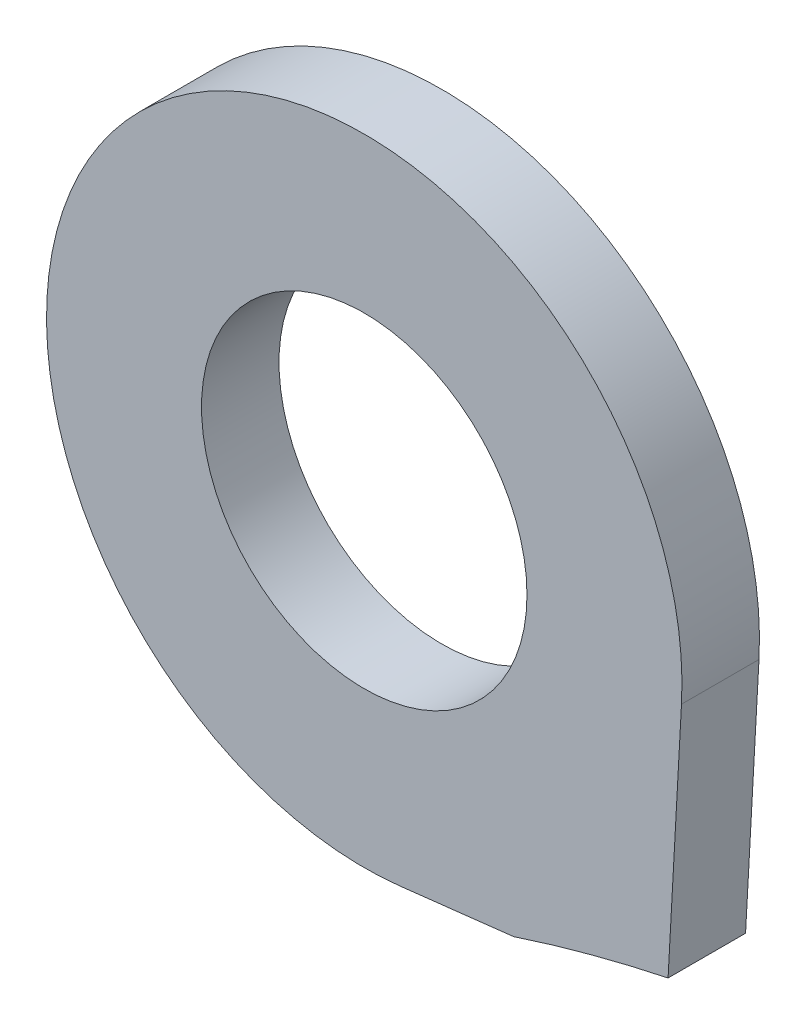
from build123d import *

# Parameters (mm, degrees)
SKETCH1_R           = 2.1
BOSS_EXTRUDE1_DEPTH = 1


with BuildPart() as part:
    # Sketch1 → Boss-Extrude1 (new body)
    with BuildSketch(Plane.XY):
        with BuildLine():
            Line((-5.822642058, -27.15591748), (-7.283078433, -27.323325945))
            ThreePointArc((-7.283078433, -27.323325945), (-10.733548038, -20.437804932), (-3.656203635, -23.475458024))
            Line((-3.656203635, -23.475458024), (-3.829485321, -26.621852742))
            ThreePointArc((-3.829485321, -26.621852742), (-4.833445667, -26.861335194), (-5.822642058, -27.15591748))
        make_face()
        with Locations((-7.75, -23.25)):
            Circle(SKETCH1_R, mode=Mode.SUBTRACT)
    extrude(amount=BOSS_EXTRUDE1_DEPTH)


solid = part.part
